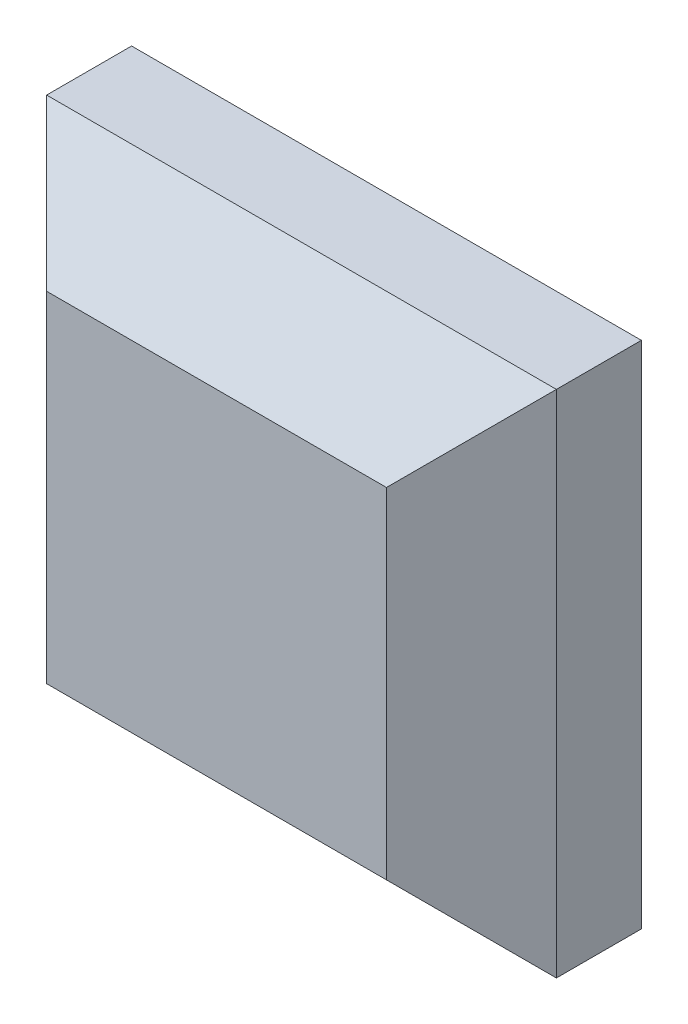
from build123d import *

# Parameters (mm, degrees)
SKETCH1_W           = 30
SKETCH1_H           = 30
BOSS_EXTRUDE1_DEPTH = 10
CHAMFER1_SIZE       = 5
SHELL1_T            = -2
BOSS_EXTRUDE2_REACH = 12


with BuildPart() as part:
    # Sketch1 → Boss-Extrude1 (new body)
    with BuildSketch(Plane.XY):
        Rectangle(SKETCH1_W, SKETCH1_H)
    extrude(amount=BOSS_EXTRUDE1_DEPTH)

    # Chamfer1
    chamfer1_edges = [part.edges().sort_by_distance(p)[0] for p in [
        (-15, 0, 10),
        (0, -15, 10),
        (15, 0, 10),
        (0, 15, 10),
    ]]
    chamfer(chamfer1_edges, length=CHAMFER1_SIZE)

    # Shell1
    shell1_openings = [part.faces().sort_by_distance(p)[0] for p in [
        (0, 0, 0),
    ]]
    offset(amount=SHELL1_T, openings=shell1_openings, kind=Kind.INTERSECTION)

    # Sketch2 → Boss-Extrude2 (add, up to next)
    with BuildSketch(Plane(origin=(0, 0, 0), x_dir=(-1, 0, 0), z_dir=(0, 0, -1)), mode=Mode.PRIVATE) as boss_extrude2_sk1:
        Polygon((13, 2.5), (2.5, 2.5), (2.5, 13), (-2.5, 13), (-2.5, 2.5), (-13, 2.5), (-13, -2.5), (-2.5, -2.5), (-2.5, -13), (2.5, -13), (2.5, -2.5), (13, -2.5), align=None)
    boss_extrude2_tool1 = extrude(boss_extrude2_sk1.sketch, amount=-BOSS_EXTRUDE2_REACH, mode=Mode.PRIVATE) - part.part
    add(boss_extrude2_tool1.solids().sort_by_distance((0, 0, 0))[0])


solid = part.part
